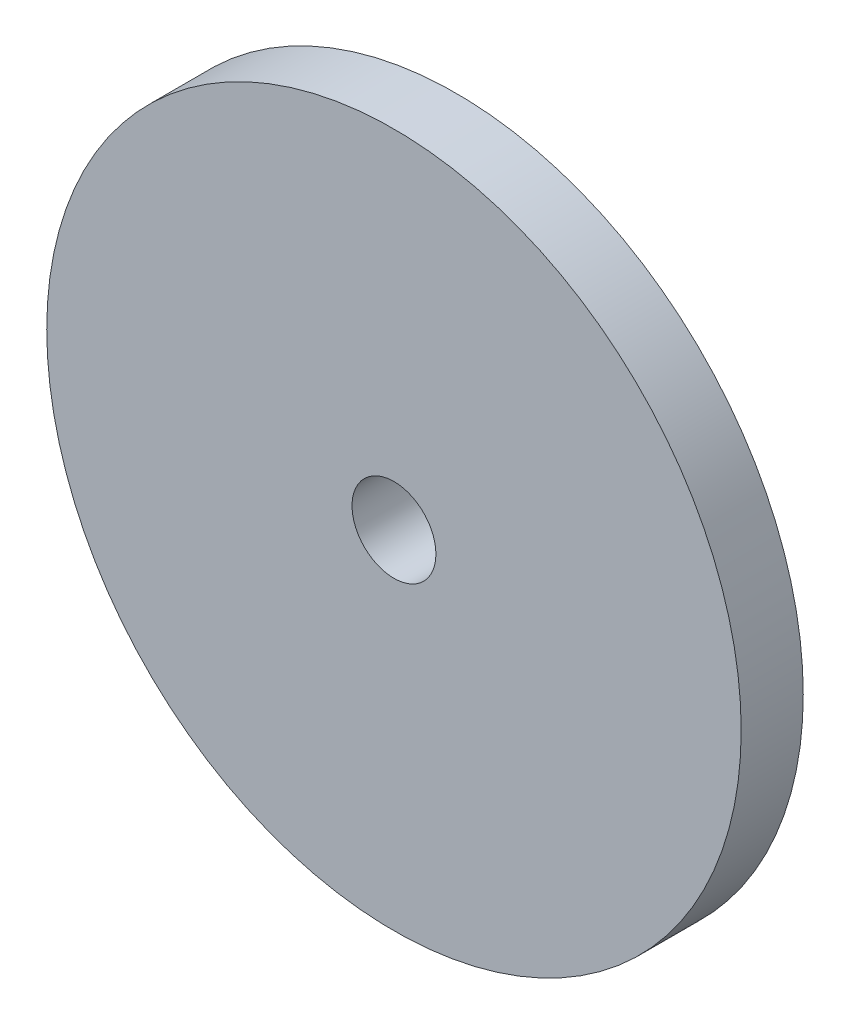
from build123d import *

# Parameters (mm, degrees)
MODEL_R                 = 16.783658254
MODEL_R_2               = 2.027709262
SALIENTE_EXTRUIR1_DEPTH = 3


with BuildPart() as part:
    # Model → Saliente-Extruir1 (new body)
    with BuildSketch(Plane.XY):
        with Locations((36.636, 18.676)):
            Circle(MODEL_R)
        with Locations((36.636, 18.676)):
            Circle(MODEL_R_2, mode=Mode.SUBTRACT)
    extrude(amount=SALIENTE_EXTRUIR1_DEPTH)


solid = part.part
